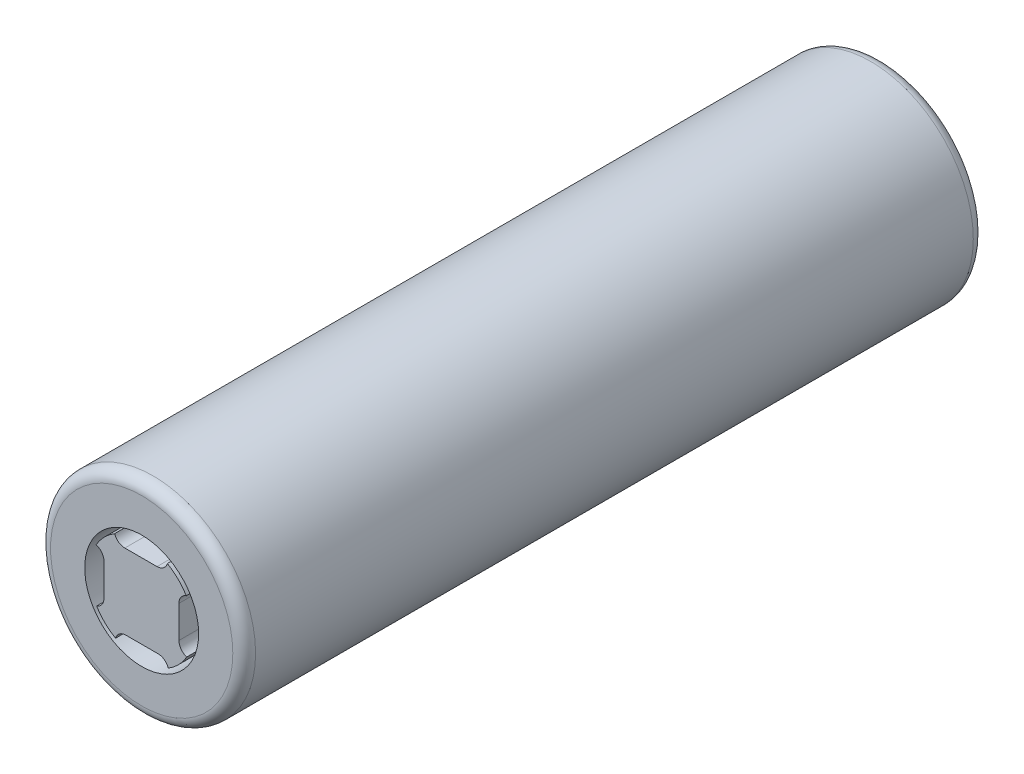
from build123d import *

# Parameters (mm, degrees)
SKETCH1_R           = 9
BOSS_EXTRUDE1_DEPTH = 65
FILLET3_R           = 1
SKETCH2_R           = 6.5
CUT_EXTRUDE1_DEPTH  = 0.02
SKETCH3_R           = 5
CUT_EXTRUDE2_DEPTH  = 3
BOSS_EXTRUDE2_DEPTH = 3.02


with BuildPart() as part:
    # Sketch1 → Boss-Extrude1 (new body)
    with BuildSketch(Plane.XY):
        Circle(SKETCH1_R)
    extrude(amount=-BOSS_EXTRUDE1_DEPTH)

    # Fillet3
    fillet3_edges = [part.edges().sort_by_distance(p)[0] for p in [
        (-9, 0, 0),
        (-9, 0, -65),
    ]]
    fillet(fillet3_edges, radius=FILLET3_R)

    # Sketch2 → Cut-Extrude1 (cut)
    with BuildSketch(Plane(origin=(0, 0, -65), x_dir=(-1, 0, 0), z_dir=(0, 0, -1))):
        Circle(SKETCH2_R)
    extrude(amount=-CUT_EXTRUDE1_DEPTH, mode=Mode.SUBTRACT)

    # Sketch3 → Cut-Extrude2 (cut)
    with BuildSketch(Plane.XY):
        Circle(SKETCH3_R)
    extrude(amount=-CUT_EXTRUDE2_DEPTH, mode=Mode.SUBTRACT)

    # Sketch5 → Boss-Extrude2 (add)
    with BuildSketch(Plane.XY.offset(-3)):
        with BuildLine():
            ThreePointArc((2.354766788, -3.930964434), (2.009586935, -3.466533841), (1.458608256, -3.289707931))
            Line((1.458608256, -3.289707931), (-1.364423568, -3.289707931))
            ThreePointArc((-1.364423568, -3.289707931), (-1.935076343, -3.480999085), (-2.275145199, -3.977577445))
            ThreePointArc((-2.275145199, -3.977577445), (-3.207386444, -3.272625889), (-3.930964434, -2.354766788))
            ThreePointArc((-3.930964434, -2.354766788), (-3.466533841, -2.009586935), (-3.289707931, -1.458608256))
            Line((-3.289707931, -1.458608256), (-3.289707931, 1.364423568))
            ThreePointArc((-3.289707931, 1.364423568), (-3.480999085, 1.935076343), (-3.977577445, 2.275145199))
            ThreePointArc((-3.977577445, 2.275145199), (-3.272625889, 3.207386444), (-2.354766788, 3.930964434))
            ThreePointArc((-2.354766788, 3.930964434), (-2.009586935, 3.466533841), (-1.458608256, 3.289707931))
            Line((-1.458608256, 3.289707931), (1.364423568, 3.289707931))
            ThreePointArc((1.364423568, 3.289707931), (1.935076343, 3.480999085), (2.275145199, 3.977577445))
            ThreePointArc((2.275145199, 3.977577445), (3.207386444, 3.272625889), (3.930964434, 2.354766788))
            ThreePointArc((3.930964434, 2.354766788), (3.466533841, 2.009586935), (3.289707931, 1.458608256))
            Line((3.289707931, 1.458608256), (3.289707931, -1.364423568))
            ThreePointArc((3.289707931, -1.364423568), (3.480999085, -1.935076343), (3.977577445, -2.275145199))
            ThreePointArc((3.977577445, -2.275145199), (3.272625889, -3.207386444), (2.354766788, -3.930964434))
        make_face()
    extrude(amount=BOSS_EXTRUDE2_DEPTH)


solid = part.part
